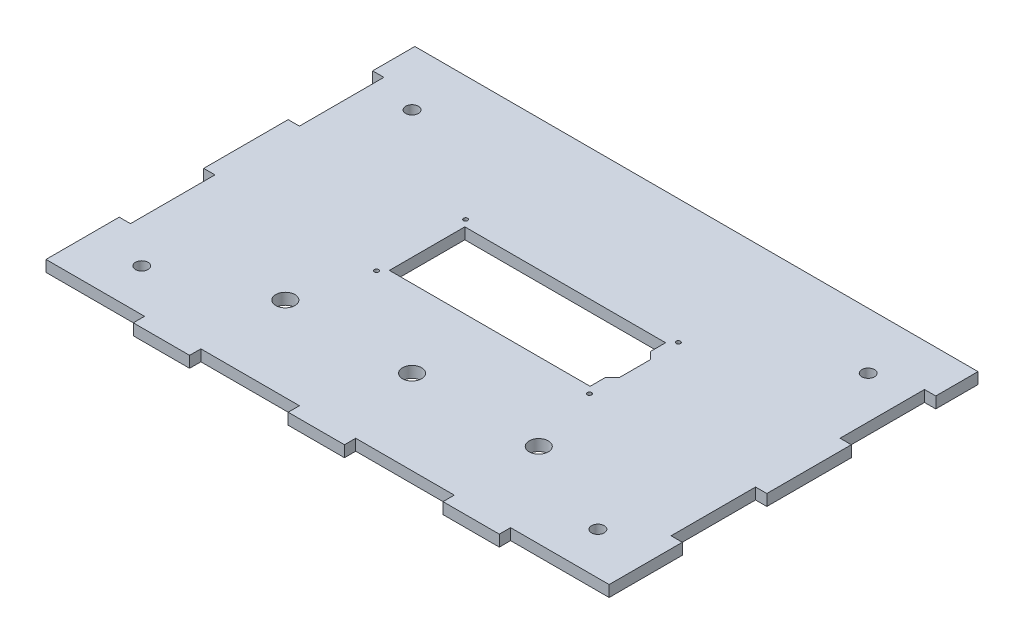
from build123d import *

# Parameters (mm, degrees)
ESBO_O1_W                = 200
ESBO_O1_H                = 150
ESBO_O1_R                = 0.75
RESSALTO_EXTRUS_O1_DEPTH = 4
ESBO_O2_W                = 35
ESBO_O2_H                = 4
ESBO_O2_W_2              = 4
ESBO_O2_H_2              = 30
CORTE_EXTRUS_O1_DEPTH    = 5
ESBO_O3_W                = 200
ESBO_O3_H                = 15
CORTE_EXTRUS_O2_DEPTH    = 5
FURO_COM_FOLGA_DE_M41_D  = 4.5
ESBO_O5_R                = 3.4
CORTE_EXTRUS_O3_DEPTH    = 5


with BuildPart() as part:
    # Esboço1 → Ressalto-extrusão1 (new body)
    with BuildSketch(Plane(origin=(0, 0, 0), x_dir=(1, 0, 0), z_dir=(0, 1, 0))):
        Rectangle(ESBO_O1_W, ESBO_O1_H)
        with Locations((-37.8, 15.8)):
            Circle(ESBO_O1_R, mode=Mode.SUBTRACT)
        with Locations((37.8, 15.8)):
            Circle(ESBO_O1_R, mode=Mode.SUBTRACT)
        with Locations((37.8, -15.8)):
            Circle(ESBO_O1_R, mode=Mode.SUBTRACT)
        with Locations((-37.8, -15.8)):
            Circle(ESBO_O1_R, mode=Mode.SUBTRACT)
        Polygon((-35.65, -13.4), (35.65, -13.4), (35.65, -8), (38.15, -5.5), (38.15, 5.5), (35.65, 8), (35.65, 13.4), (-35.65, 13.4), align=None, mode=Mode.SUBTRACT)
    extrude(amount=RESSALTO_EXTRUS_O1_DEPTH)

    # Esboço2 → Corte-extrusão1 (cut, through all)
    with BuildSketch(Plane(origin=(0, 4, 0), x_dir=(1, 0, 0), z_dir=(0, 1, 0))):
        with Locations((-27.5, -73)):
            Rectangle(ESBO_O2_W, ESBO_O2_H)
        with Locations((27.5, -73)):
            Rectangle(ESBO_O2_W, ESBO_O2_H)
        with Locations((82.5, -73)):
            Rectangle(ESBO_O2_W, ESBO_O2_H)
        with Locations((-82.5, -73)):
            Rectangle(ESBO_O2_W, ESBO_O2_H)
        with Locations((98, 30)):
            Rectangle(ESBO_O2_W_2, ESBO_O2_H_2)
        with Locations((98, -30)):
            Rectangle(ESBO_O2_W_2, ESBO_O2_H_2)
        with Locations((-98, 30)):
            Rectangle(ESBO_O2_W_2, ESBO_O2_H_2)
        with Locations((-98, -30)):
            Rectangle(ESBO_O2_W_2, ESBO_O2_H_2)
    extrude(amount=-CORTE_EXTRUS_O1_DEPTH, mode=Mode.SUBTRACT)

    # Esboço3 → Corte-extrusão2 (cut, through all)
    with BuildSketch(Plane(origin=(0, 4, 0), x_dir=(1, 0, 0), z_dir=(0, 1, 0))):
        with Locations((0, 67.5)):
            Rectangle(ESBO_O3_W, ESBO_O3_H)
    extrude(amount=-CORTE_EXTRUS_O2_DEPTH, mode=Mode.SUBTRACT)

    # Furo com folga de M41 (through all)
    with Locations(Plane(origin=(-81, 4, -40), x_dir=(0, 0, 1), z_dir=(0, 1, 0))):
        with Locations((0, 0), (96, 0), (96, 162), (0, 162)):
            Hole(FURO_COM_FOLGA_DE_M41_D / 2)

    # Esboço5 → Corte-extrusão3 (cut, through all)
    with BuildSketch(Plane(origin=(0, 4, 0), x_dir=(1, 0, 0), z_dir=(0, 1, 0))):
        with Locations((-45, -41)):
            Circle(ESBO_O5_R)
        with Locations((0, -41)):
            Circle(ESBO_O5_R)
        with Locations((45, -41)):
            Circle(ESBO_O5_R)
    extrude(amount=-CORTE_EXTRUS_O3_DEPTH, mode=Mode.SUBTRACT)


solid = part.part
